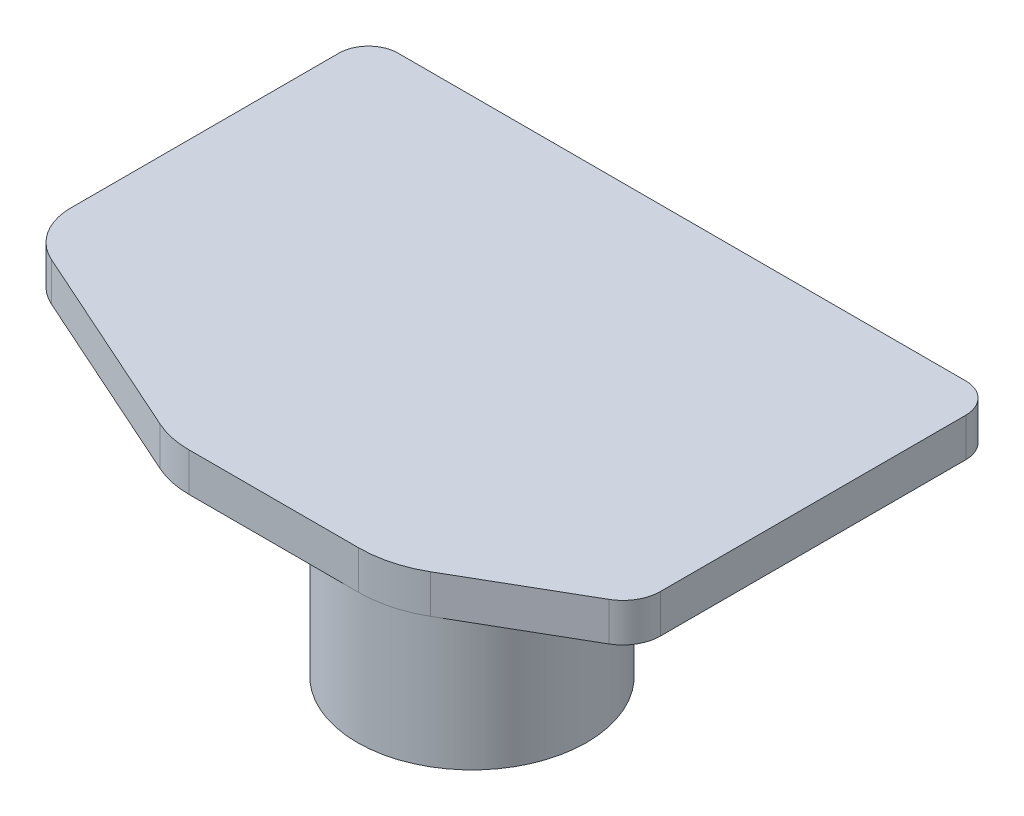
from build123d import *

# Parameters (mm, degrees)
BOSS_EXTRUDE2_DEPTH = 13
SKETCH3_R           = 38.614889052
BOSS_EXTRUDE3_DEPTH = 44


with BuildPart() as part:
    # Sketch1 → Boss-Extrude2 (new body)
    with BuildSketch(Plane(origin=(0, 0, 0), x_dir=(1, 0, 0), z_dir=(0, 1, 0))):
        with BuildLine():
            Line((132.11743751, -48.51341168), (94.01743751, -70.510456937))
            ThreePointArc((94.01743751, -70.510456937), (84.828443129, -74.316663034), (74.96743751, -75.614889052))
            Line((74.96743751, -75.614889052), (17.81743751, -75.614889052))
            ThreePointArc((17.81743751, -75.614889052), (11.548173881, -74.952515636), (5.555749824, -72.994644622))
            Line((5.555749824, -72.994644622), (-60.707020947, -43.319675524))
            ThreePointArc((-60.707020947, -43.319675524), (-69.317811507, -35.941035728), (-72.53256249, -25.066505144))
            Line((-72.53256249, -25.066505144), (-72.53256249, 65.185110948))
            ThreePointArc((-72.53256249, 65.185110948), (-69.603630301, 72.256178759), (-62.53256249, 75.185110948))
            Line((-62.53256249, 75.185110948), (128.46743751, 75.185110948))
            ThreePointArc((128.46743751, 75.185110948), (135.538505322, 72.256178759), (138.46743751, 65.185110948))
            Line((138.46743751, 65.185110948), (138.46743751, -37.514889052))
            ThreePointArc((138.46743751, -37.514889052), (136.765960139, -43.864889052), (132.11743751, -48.51341168))
        make_face()
    extrude(amount=BOSS_EXTRUDE2_DEPTH)

    # Sketch3 → Boss-Extrude3 (add)
    with BuildSketch(Plane(origin=(0, 0, 0), x_dir=(1, 0, 0), z_dir=(0, 1, 0))):
        with Locations((74.46743751, -37)):
            Circle(SKETCH3_R)
    extrude(amount=-BOSS_EXTRUDE3_DEPTH)


solid = part.part
